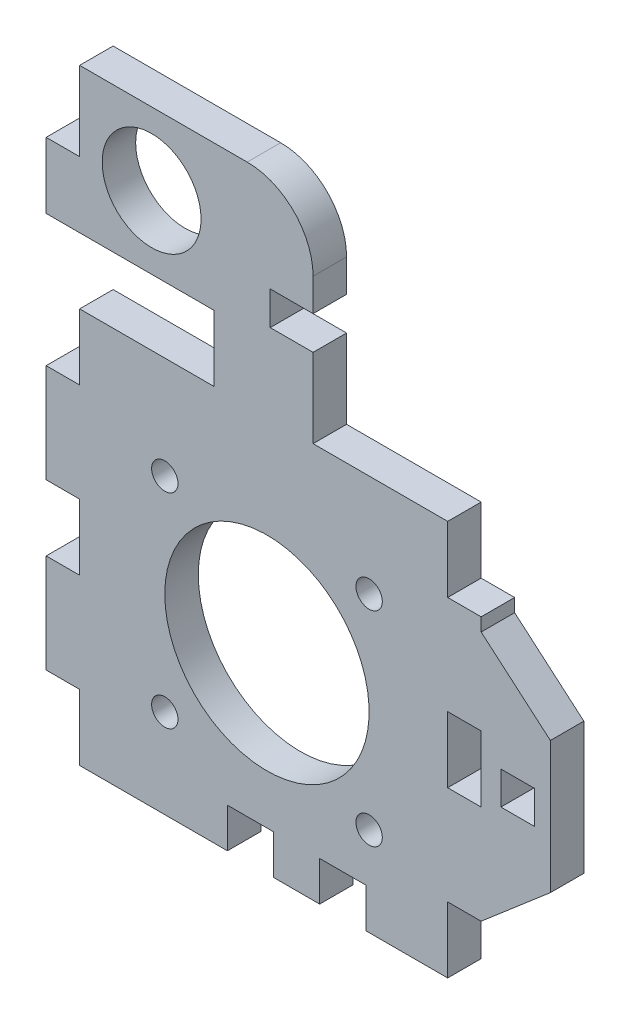
from build123d import *

# Parameters (mm, degrees)
BOSS_EXTRUDE1_DEPTH = 5.08
SKETCH2_R           = 15.5
SKETCH2_R_2         = 2
SKETCH2_W           = 7
SKETCH2_H           = 6
SKETCH2_W_2         = 5.08
SKETCH2_H_2         = 5
CUT_EXTRUDE1_DEPTH  = 6.08
SKETCH4_W           = 5.08
SKETCH4_H           = 10
CUT_EXTRUDE2_DEPTH  = 6.08
SKETCH5_R           = 7.5
BOSS_EXTRUDE2_DEPTH = 5.08
SKETCH6_W           = 5.08
SKETCH6_H           = 12
SKETCH6_W_2         = 8
SKETCH6_H_2         = 5.08
CUT_EXTRUDE3_DEPTH  = 6.08
FILLET1_R           = 10


with BuildPart() as part:
    # Sketch1 → Boss-Extrude1 (new body)
    with BuildSketch(Plane.XY):
        Polygon((32.5, 19), (43, 10), (43, -10), (32.5, -19), (32.5, -29), (-33.5, -29), (-33.5, 31), (32.5, 31), align=None)
    extrude(amount=BOSS_EXTRUDE1_DEPTH)

    # Sketch2 → Cut-Extrude1 (cut, through all)
    with BuildSketch(Plane(origin=(0, 0, 0), x_dir=(-1, 0, 0), z_dir=(0, 0, -1))):
        Circle(SKETCH2_R)
        with Locations((15.5, -15.5)):
            Circle(SKETCH2_R_2)
        with Locations((-15.5, -15.5)):
            Circle(SKETCH2_R_2)
        with Locations((-15.5, 15.5)):
            Circle(SKETCH2_R_2)
        with Locations((15.5, 15.5)):
            Circle(SKETCH2_R_2)
        with Locations((-11.5, -26)):
            Rectangle(SKETCH2_W, SKETCH2_H)
        with Locations((2.5, -26)):
            Rectangle(SKETCH2_W, SKETCH2_H)
        with Locations((-38.04, 0)):
            Rectangle(SKETCH2_W_2, SKETCH2_H_2)
    extrude(amount=-CUT_EXTRUDE1_DEPTH, mode=Mode.SUBTRACT)

    # Sketch4 → Cut-Extrude2 (cut, through all)
    with BuildSketch(Plane.XY.offset(5.08)):
        with Locations((29.96, 1)):
            Rectangle(SKETCH4_W, SKETCH4_H)
        with Locations((29.96, -24)):
            Rectangle(SKETCH4_W, SKETCH4_H)
        with Locations((29.96, 26)):
            Rectangle(SKETCH4_W, SKETCH4_H)
        with Locations((-30.96, -24)):
            Rectangle(SKETCH4_W, SKETCH4_H)
        with Locations((-30.96, 1)):
            Rectangle(SKETCH4_W, SKETCH4_H)
        with Locations((-30.96, 26)):
            Rectangle(SKETCH4_W, SKETCH4_H)
    extrude(amount=-CUT_EXTRUDE2_DEPTH, mode=Mode.SUBTRACT)

    # Sketch5 → Boss-Extrude2 (add)
    with BuildSketch(Plane.XY.offset(5.08)):
        Polygon((-8, 63), (7, 63), (7, 31), (-8, 31), (-8, 41), (-33.5, 41), (-33.5, 63), align=None)
        with Locations((-17.5, 52)):
            Circle(SKETCH5_R, mode=Mode.SUBTRACT)
    extrude(amount=-BOSS_EXTRUDE2_DEPTH)

    # Sketch6 → Cut-Extrude3 (cut, through all)
    with BuildSketch(Plane.XY.offset(5.08)):
        with Locations((-30.96, 57)):
            Rectangle(SKETCH6_W, SKETCH6_H)
        with Locations((4.5, 45.54)):
            Rectangle(SKETCH6_W_2, SKETCH6_H_2)
    extrude(amount=-CUT_EXTRUDE3_DEPTH, mode=Mode.SUBTRACT)

    # Fillet1
    fillet1_edges = [part.edges().sort_by_distance(p)[0] for p in [
        (7, 63, 2.54),
    ]]
    fillet(fillet1_edges, radius=FILLET1_R)


solid = part.part
